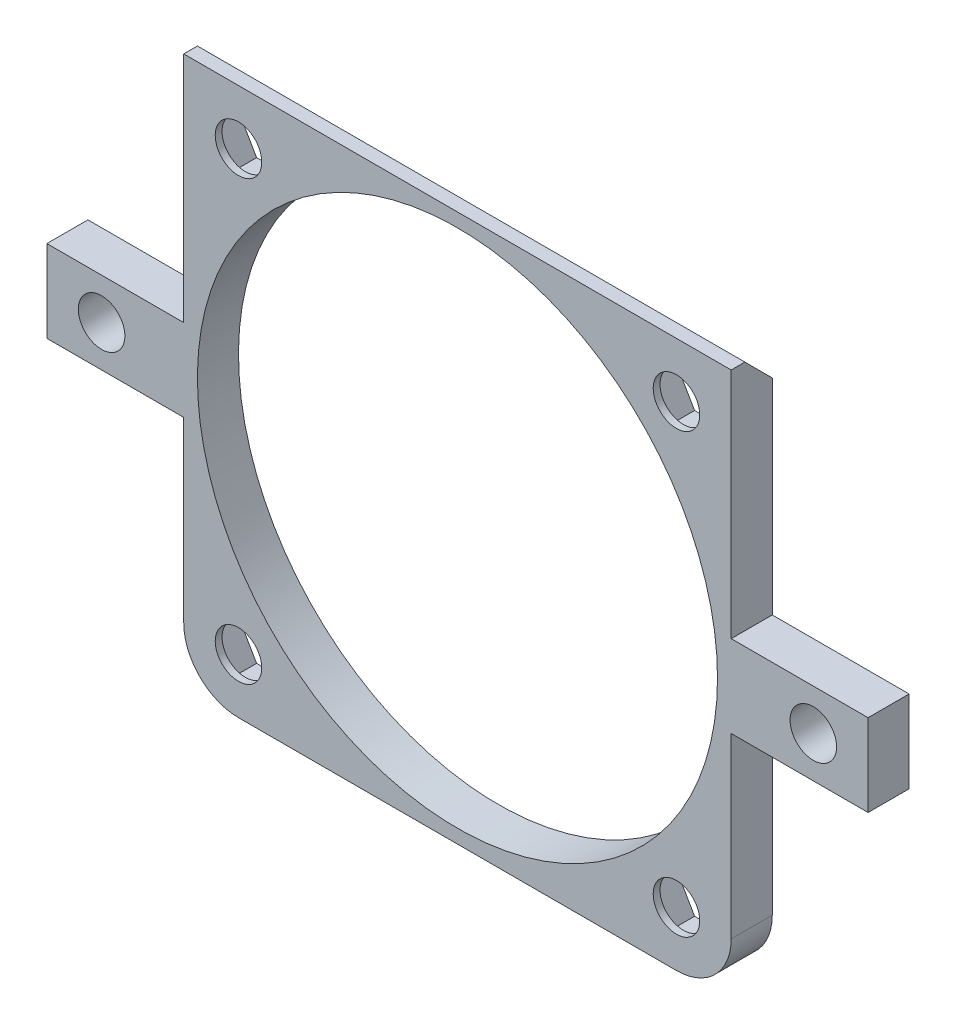
from build123d import *

# Parameters (mm, degrees)
CROQUIS1_R              = 19
CROQUIS1_R_2            = 1.7
SALIENTE_EXTRUIR1_DEPTH = 3
CORTAR_EXTRUIR1_DEPTH   = 40
REDONDEO1_R             = 4
CORTAR_EXTRUIR2_DEPTH   = 2.5


with BuildPart() as part:
    # Croquis1 → Saliente-Extruir1 (new body)
    with BuildSketch(Plane.XY):
        Polygon((-30, 3), (-30, -3), (-20, -3), (-20, -20), (20, -20), (20, -3), (30, -3), (30, 3), (20, 3), (20, 20), (-20, 20), (-20, 3), align=None)
        Circle(CROQUIS1_R, mode=Mode.SUBTRACT)
        with Locations((-26, 0)):
            Circle(CROQUIS1_R_2, mode=Mode.SUBTRACT)
        with Locations((26, 0)):
            Circle(CROQUIS1_R_2, mode=Mode.SUBTRACT)
        with Locations((16, 16)):
            Circle(CROQUIS1_R_2, mode=Mode.SUBTRACT)
        with Locations((-16, 16)):
            Circle(CROQUIS1_R_2, mode=Mode.SUBTRACT)
        with Locations((-16, -16)):
            Circle(CROQUIS1_R_2, mode=Mode.SUBTRACT)
        with Locations((16, -16)):
            Circle(CROQUIS1_R_2, mode=Mode.SUBTRACT)
    extrude(amount=SALIENTE_EXTRUIR1_DEPTH)

    # Croquis2 → Cortar-Extruir1 (cut)
    with BuildSketch(Plane.ZY.offset(20)):
        Polygon((2, 20), (0, 20), (0, 18), align=None)
    extrude(amount=-CORTAR_EXTRUIR1_DEPTH, mode=Mode.SUBTRACT)

    # Redondeo1
    redondeo1_edges = [part.edges().sort_by_distance(p)[0] for p in [
        (20, -20, 1.5),
        (-20, -20, 1.5),
    ]]
    fillet(redondeo1_edges, radius=REDONDEO1_R)

    # Croquis3 → Cortar-Extruir2 (cut)
    with BuildSketch(Plane(origin=(0, 0, 0), x_dir=(-1, 0, 0), z_dir=(0, 0, -1))):
        Polygon((-12.65, 16), (-14.325, 18.901185103), (-17.675, 18.901185103), (-19.35, 16), (-17.675, 13.098814897), (-14.325, 13.098814897), align=None)
        Polygon((-12.65, -16), (-14.325, -13.098814897), (-17.675, -13.098814897), (-19.35, -16), (-17.675, -18.901185103), (-14.325, -18.901185103), align=None)
        Polygon((19.35, -16), (17.675, -13.098814897), (14.325, -13.098814897), (12.65, -16), (14.325, -18.901185103), (17.675, -18.901185103), align=None)
        Polygon((19.35, 16), (17.675, 18.901185103), (14.325, 18.901185103), (12.65, 16), (14.325, 13.098814897), (17.675, 13.098814897), align=None)
    extrude(amount=-CORTAR_EXTRUIR2_DEPTH, mode=Mode.SUBTRACT)


solid = part.part
